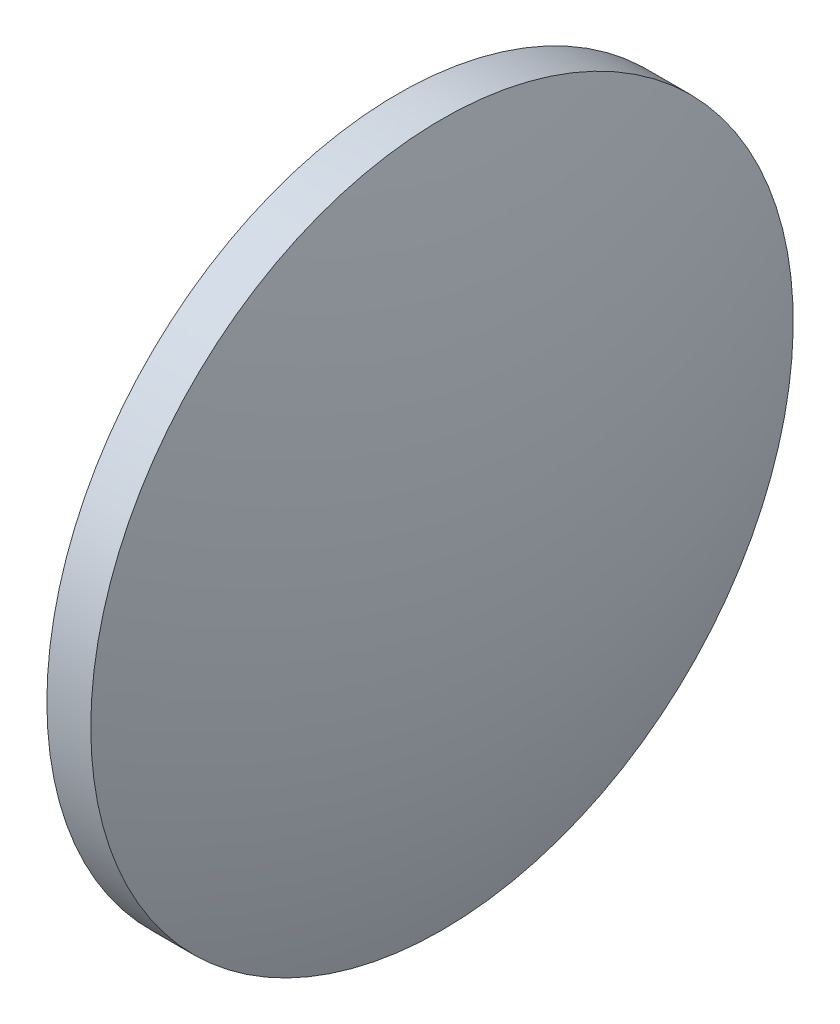
from build123d import *


with BuildPart() as part:
    # 草图1 → 旋转1 (revolve)
    with BuildSketch(Plane.XY, mode=Mode.PRIVATE) as revolve_1_sk:
        with BuildLine():
            Line((626.62320002, 80.189467728), (626.62320002, 100.189467728))
            Line((626.62320002, 100.189467728), (629.12320002, 100.189467728))
            ThreePointArc((629.12320002, 100.189467728), (631.503237948, 90.315083759), (632.30320002, 80.189467728))
            Line((632.30320002, 80.189467728), (626.62320002, 80.189467728))
        make_face()
    revolve(revolve_1_sk.sketch.rotate(Axis((621.928656839, 80.189467728, 0), (1, 0, 0)), 180), axis=Axis((621.928656839, 80.189467728, 0), (1, 0, 0)))  # turned: the seam where the file's is


solid = part.part
